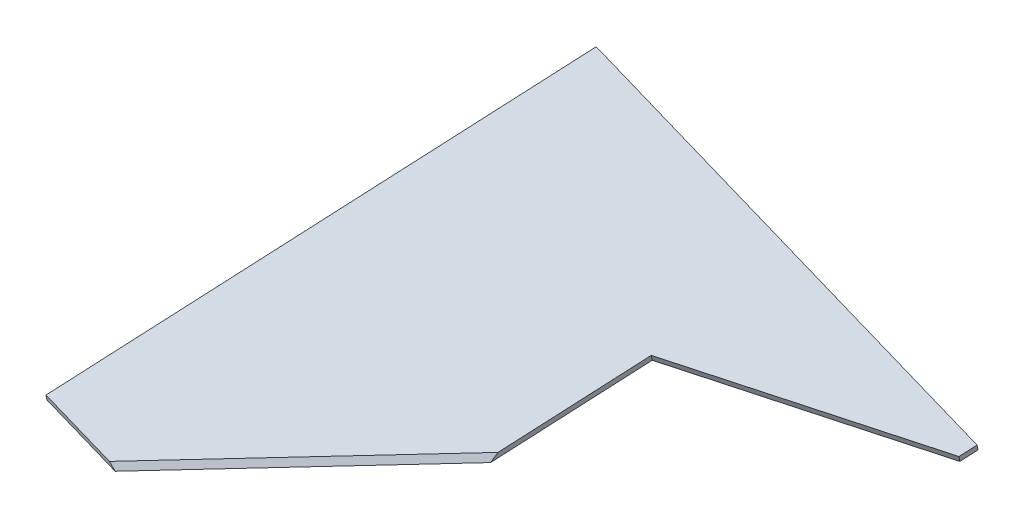
from build123d import *

# Parameters (mm, degrees)
BOSS_EXTRUDE1_DEPTH = 3
CUT_EXTRUDE2_DEPTH  = 80
BOSS_EXTRUDE2_DEPTH = 3


with BuildPart() as part:
    # Sketch1 → Boss-Extrude1 (new body)
    with BuildSketch(Plane(origin=(40.618995436, 405.717520436, 71.391276418), x_dir=(0.935705749, -0.202672232, 0.288753733), z_dir=(-0.118950757, -0.951829224, -0.282616075))):
        Polygon((-9.093557887, 199.496352052), (122.645886532, 181.228380511), (87.83671653, -69.797887318), (-43.902727889, -51.529915777), align=None)
    extrude(amount=-BOSS_EXTRUDE1_DEPTH)

    # Sketch3 → Cut-Extrude2 (cut)
    with BuildSketch(Plane(origin=(184.762741438, 119.897305559, 240.069514855), x_dir=(0.516756682, 0.537673014, -0.66623589), z_dir=(0.567103814, 0.368008283, 0.736860345))):
        Polygon((970.937778761, -219.886702224), (970.937778761, 845.245168422), (-1124.286512281, 775.631358808), (-1124.286512281, -289.500511838), align=None)
    extrude(amount=CUT_EXTRUDE2_DEPTH, mode=Mode.SUBTRACT)

    # Sketch4 → Boss-Extrude2 (add)
    with BuildSketch(Plane(origin=(48.910383393, 391.374830059, 116.206579281), x_dir=(0.992857215, -0.11667261, -0.024940964), z_dir=(-0.118950757, -0.951829224, -0.282616075))):
        Polygon((83.713958284, -16.750212929), (96.993345394, -84.345811369), (209.443931521, -62.254508112), (207.834795901, -54.063581501), align=None)
    extrude(amount=-BOSS_EXTRUDE2_DEPTH)


solid = part.part
